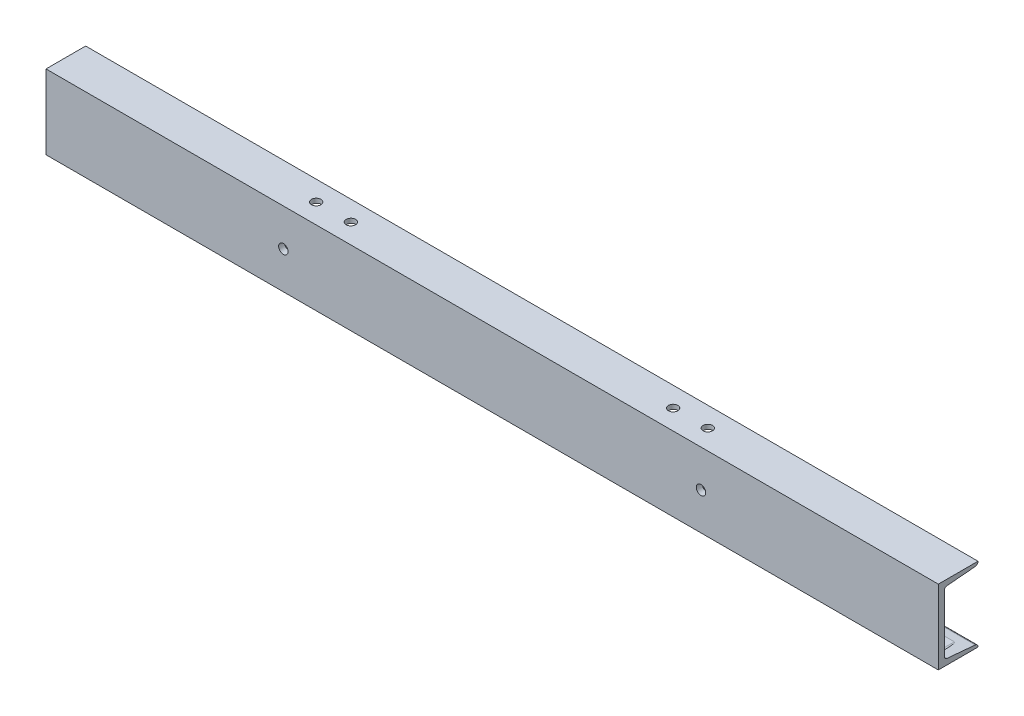
from build123d import *

# Parameters (mm, degrees)
STRUCTURAL_MEMBER1_DEPTH = 900
SKETCH12_R               = 4.7625
CUT_EXTRUDE1_DEPTH       = 454.327971782
CUT_EXTRUDE2_DEPTH       = 40
SKETCH16_R               = 4.7625
CUT_EXTRUDE3_DEPTH       = 454.327971881
SKETCH17_R               = 4.7625
CUT_EXTRUDE4_DEPTH       = 454.327971881


with BuildPart() as part:
    # Sketch112 → Structural Member1 (new body)
    with BuildSketch(Plane(origin=(-450, 0, 0), x_dir=(0, 0, 1), z_dir=(1, 0, 0))):
        with BuildLine():
            Line((0, 37.5), (0, -37.5))
            Line((0, -37.5), (-40, -37.5))
            Line((-40, -37.5), (-40, -37.246949676))
            ThreePointArc((-40, -37.246949676), (-39.212582687, -35.220998578), (-37.263681431, -34.258560126))
            Line((-37.263681431, -34.258560126), (-8.736318569, -31.741439874))
            ThreePointArc((-8.736318569, -31.741439874), (-6.787417313, -30.779001422), (-6, -28.753050324))
            Line((-6, -28.753050324), (-6, 28.753050324))
            ThreePointArc((-6, 28.753050324), (-6.787417313, 30.779001422), (-8.736318569, 31.741439874))
            Line((-8.736318569, 31.741439874), (-37.263681431, 34.258560126))
            ThreePointArc((-37.263681431, 34.258560126), (-39.212582687, 35.220998578), (-40, 37.246949676))
            Line((-40, 37.246949676), (-40, 37.5))
            Line((-40, 37.5), (0, 37.5))
        make_face()
    extrude(amount=STRUCTURAL_MEMBER1_DEPTH)

    # Sketch12 → Cut-Extrude1 (cut, through all)
    with BuildSketch(Plane(origin=(0, 0, 0), x_dir=(1, 0, 0), z_dir=(0, 1, 0))):
        with Locations(Location((-425, 20, 0), (0, 0, 270))):
            Circle(SKETCH12_R)
        with Locations(Location((425, 20, 0), (0, 0, 270))):
            Circle(SKETCH12_R)
    extrude(amount=-CUT_EXTRUDE1_DEPTH, mode=Mode.SUBTRACT)

    # Sketch15 → Cut-Extrude2 (cut)
    with BuildSketch(Plane(origin=(0, 0, -6), x_dir=(-1, 0, 0), z_dir=(0, 0, -1))):
        with BuildLine():
            Line((-412.5, -33.5), (-437.5, -33.5))
            ThreePointArc((-437.5, -33.5), (-442.5, -28.5), (-437.5, -23.5))
            Line((-437.5, -23.5), (-412.5, -23.5))
            ThreePointArc((-412.5, -23.5), (-407.5, -28.5), (-412.5, -33.5))
        make_face()
        with BuildLine():
            Line((412.5, -33.5), (437.5, -33.5))
            ThreePointArc((437.5, -33.5), (442.5, -28.5), (437.5, -23.5))
            Line((437.5, -23.5), (412.5, -23.5))
            ThreePointArc((412.5, -23.5), (407.5, -28.5), (412.5, -33.5))
        make_face()
    extrude(amount=CUT_EXTRUDE2_DEPTH, mode=Mode.SUBTRACT)

    # Sketch16 → Cut-Extrude3 (cut, through all)
    with BuildSketch(Plane(origin=(0, 0, 0), x_dir=(1, 0, 0), z_dir=(0, 1, 0))):
        with Locations(Location((-197.5, 20, 0), (0, 0, 270))):
            Circle(SKETCH16_R)
        with Locations(Location((-162.5, 20, 0), (0, 0, 270))):
            Circle(SKETCH16_R)
        with Locations(Location((162.5, 20, 0), (0, 0, 90))):
            Circle(SKETCH16_R)
        with Locations(Location((197.5, 20, 0), (0, 0, 90))):
            Circle(SKETCH16_R)
    extrude(amount=CUT_EXTRUDE3_DEPTH, mode=Mode.SUBTRACT)

    # Sketch17 → Cut-Extrude4 (cut, through all)
    with BuildSketch(Plane.XY):
        with Locations((-210.6, 0)):
            Circle(SKETCH17_R)
        with Locations((210.6, 0)):
            Circle(SKETCH17_R)
    extrude(amount=-CUT_EXTRUDE4_DEPTH, mode=Mode.SUBTRACT)


solid = part.part
